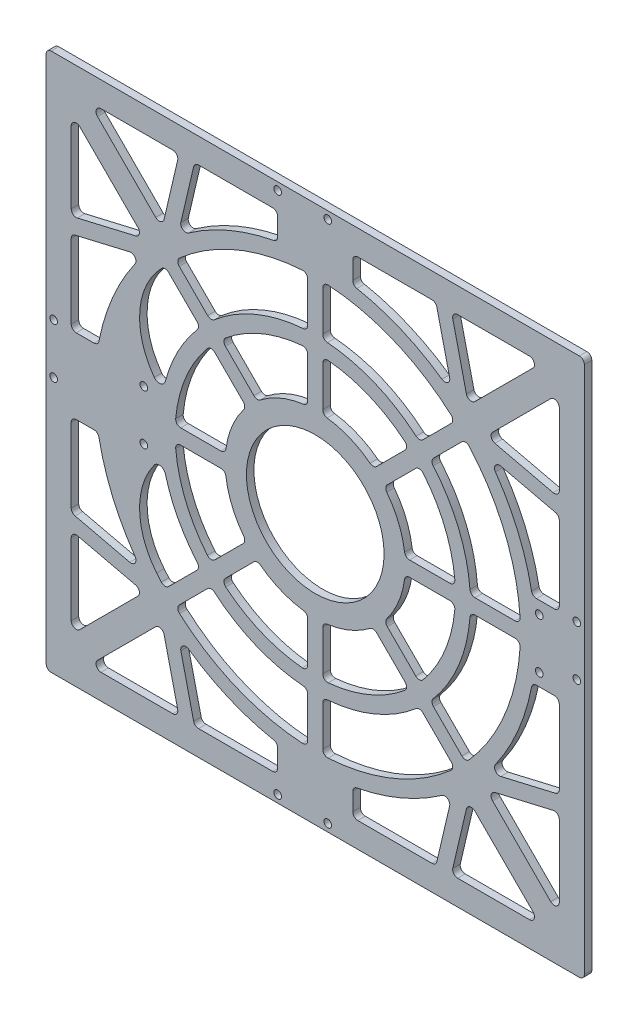
from build123d import *

# Parameters (mm, degrees)
SKETCH_1_W                  = 215
SKETCH_1_H                  = 215
EXTRUDE_1_DEPTH             = 1.5
SKETCH_2_R                  = 2.5
CUT_EXTRUDE_1_DEPTH         = 10
SKETCH_3_R                  = 1.525
CUT_EXTRUDE_2_DEPTH         = 30
HOLE_WIZARD_M3_1_AT_2_COUNT = 2
HOLE_WIZARD_M3_1_AT_2_PITCH = 22
HOLE_WIZARD_M3_1_AT_3_COUNT = 2
HOLE_WIZARD_M3_1_AT_3_PITCH = 38.105117767
HOLE_WIZARD_M3_1_AT_4_COUNT = 2
HOLE_WIZARD_M3_1_AT_4_PITCH = 44
HOLE_WIZARD_M3_1_AT_5_COUNT = 2
HOLE_WIZARD_M3_1_AT_5_PITCH = 38.105117767
HOLE_WIZARD_M3_1_AT_6_COUNT = 2
HOLE_WIZARD_M3_1_AT_6_PITCH = 22
SKETCH_6_R                  = 1.525
CUT_EXTRUDE_3_DEPTH         = 10
SKETCH_7_R                  = 1.525
CUT_EXTRUDE_4_DEPTH         = 10
CUT_EXTRUDE_5_DEPTH         = 10
FILLET_1_R                  = 2
FILLET_2_R                  = 2
CUT_EXTRUDE_6_DEPTH         = 10
PATTERN_CIRCULAR_1_COUNT    = 4
FILLET_3_R                  = 2
EXTRUDE_2_DEPTH             = 3
PATTERN_CIRCULAR_2_COUNT    = 4
FILLET_4_R                  = 2
EXTRUDE_3_DEPTH             = 3
PATTERN_CIRCULAR_3_COUNT    = 4
FILLET_5_R                  = 2
SKETCH_12_R                 = 36
EXTRUDE_4_DEPTH             = 3
SKETCH_13_R                 = 27.5
CUT_EXTRUDE_7_DEPTH         = 3
EXTRUDE_5_DEPTH             = 3
SKETCH_15_R                 = 1.525
CUT_EXTRUDE_8_DEPTH         = 10


with BuildPart() as part:
    # Sketch 1 → Extrude 1 (new body, symmetric)
    with BuildSketch(Plane.XY):
        Rectangle(SKETCH_1_W, SKETCH_1_H)
    extrude(amount=EXTRUDE_1_DEPTH, both=True)

    # Sketch 2 → Cut-Extrude 1 (cut)
    with BuildSketch(Plane.XY.offset(1.5)):
        Circle(SKETCH_2_R)
    extrude(amount=-CUT_EXTRUDE_1_DEPTH, mode=Mode.SUBTRACT)

    # Sketch 3 → Cut-Extrude 2 (cut)
    with BuildSketch(Plane.XY.offset(1.5)):
        with Locations((0, 22)):
            Circle(SKETCH_3_R)
        with Locations((19.052558883, 11)):
            Circle(SKETCH_3_R)
        with Locations((19.052558883, -11)):
            Circle(SKETCH_3_R)
        with Locations((0, -22)):
            Circle(SKETCH_3_R)
        with Locations((-19.052558883, -11)):
            Circle(SKETCH_3_R)
        with Locations((-19.052558883, 11)):
            Circle(SKETCH_3_R)
    extrude(amount=-CUT_EXTRUDE_2_DEPTH, mode=Mode.SUBTRACT)

    # Sketch 5 → Hole Wizard M3 _1 (revolve, cut)
    with BuildSketch(Plane(origin=(0, 22, -1.5), x_dir=(0, 1, 0), z_dir=(1, 0, 0))):
        Polygon((0, 0), (0, 3), (1.5, 3), (1.5, 1.8), (3.3, 0), align=None)
    hole_wizard_m3_1 = revolve(axis=Axis((0, 22, -7.85), (0, 0, 1)), mode=Mode.SUBTRACT)

    # Hole Wizard M3 _1 at 2: Hole Wizard M3 _1 ×2
    with Locations(*[Vector(-0.866025404, -0.5, 0) * (i * HOLE_WIZARD_M3_1_AT_2_PITCH) for i in range(1, HOLE_WIZARD_M3_1_AT_2_COUNT)]):
        add(hole_wizard_m3_1, mode=Mode.SUBTRACT)

    # Hole Wizard M3 _1 at 3: Hole Wizard M3 _1 ×2
    with Locations(*[Vector(-0.5, -0.866025404, 0) * (i * HOLE_WIZARD_M3_1_AT_3_PITCH) for i in range(1, HOLE_WIZARD_M3_1_AT_3_COUNT)]):
        add(hole_wizard_m3_1, mode=Mode.SUBTRACT)

    # Hole Wizard M3 _1 at 4: Hole Wizard M3 _1 ×2
    with Locations(*[(0, -i * HOLE_WIZARD_M3_1_AT_4_PITCH, 0) for i in range(1, HOLE_WIZARD_M3_1_AT_4_COUNT)]):
        add(hole_wizard_m3_1, mode=Mode.SUBTRACT)

    # Hole Wizard M3 _1 at 5: Hole Wizard M3 _1 ×2
    with Locations(*[Vector(0.5, -0.866025404, 0) * (i * HOLE_WIZARD_M3_1_AT_5_PITCH) for i in range(1, HOLE_WIZARD_M3_1_AT_5_COUNT)]):
        add(hole_wizard_m3_1, mode=Mode.SUBTRACT)

    # Hole Wizard M3 _1 at 6: Hole Wizard M3 _1 ×2
    with Locations(*[Vector(0.866025404, -0.5, 0) * (i * HOLE_WIZARD_M3_1_AT_6_PITCH) for i in range(1, HOLE_WIZARD_M3_1_AT_6_COUNT)]):
        add(hole_wizard_m3_1, mode=Mode.SUBTRACT)

    # Sketch 6 → Cut-Extrude 3 (cut)
    with BuildSketch(Plane.XY.offset(1.5)):
        with Locations((5, -104.5)):
            Circle(SKETCH_6_R)
        with Locations((-15, -104.5)):
            Circle(SKETCH_6_R)
    cut_extrude_3 = extrude(amount=-CUT_EXTRUDE_3_DEPTH, mode=Mode.SUBTRACT)

    # Mirror 1: Cut-Extrude 3 across plane
    add(cut_extrude_3.mirror(Plane.ZX), mode=Mode.SUBTRACT)

    # Sketch 7 → Cut-Extrude 4 (cut)
    with BuildSketch(Plane(origin=(0, 0, -1.5), x_dir=(-1, 0, 0), z_dir=(0, 0, -1))):
        with Locations((104.5, 15)):
            Circle(SKETCH_7_R)
        with Locations((104.5, -5)):
            Circle(SKETCH_7_R)
    cut_extrude_4 = extrude(amount=-CUT_EXTRUDE_4_DEPTH, mode=Mode.SUBTRACT)

    # Mirror 2: Cut-Extrude 4 across plane
    add(cut_extrude_4.mirror(Plane(origin=(0, 0, 0), x_dir=(0, 0, 1), z_dir=(1, 0, 0))), mode=Mode.SUBTRACT)

    # Sketch 8 → Cut-Extrude 5 (cut)
    with BuildSketch(Plane(origin=(0, 0, -1.5), x_dir=(-1, 0, 0), z_dir=(0, 0, -1))):
        with BuildLine():
            Line((3, -61.927376822), (3, -81.945103576))
            ThreePointArc((3, -81.945103576), (31.380041454, -75.758121666), (55.82261808, -60.065258767))
            Line((55.82261808, -60.065258767), (41.667947748, -45.910588435))
            ThreePointArc((41.667947748, -45.910588435), (23.726372807, -57.280531016), (3, -61.927376822))
        make_face()
        with BuildLine():
            ThreePointArc((60.065258767, -55.82261808), (75.758121666, -31.380041454), (81.945103576, -3))
            Line((81.945103576, -3), (61.927376822, -3))
            ThreePointArc((61.927376822, -3), (57.280531016, -23.726372807), (45.910588435, -41.667947748))
            Line((45.910588435, -41.667947748), (60.065258767, -55.82261808))
        make_face()
        with BuildLine():
            ThreePointArc((81.945103576, 3), (75.758121666, 31.380041454), (60.065258767, 55.82261808))
            Line((60.065258767, 55.82261808), (45.910588435, 41.667947748))
            ThreePointArc((45.910588435, 41.667947748), (57.280531016, 23.726372807), (61.927376822, 3))
            Line((61.927376822, 3), (81.945103576, 3))
        make_face()
        with BuildLine():
            ThreePointArc((55.82261808, 60.065258767), (31.380041454, 75.758121666), (3, 81.945103576))
            Line((3, 81.945103576), (3, 61.927376822))
            ThreePointArc((3, 61.927376822), (23.726372807, 57.280531016), (41.667947748, 45.910588435))
            Line((41.667947748, 45.910588435), (55.82261808, 60.065258767))
        make_face()
        with BuildLine():
            ThreePointArc((-3, 81.945103576), (-31.380041454, 75.758121666), (-55.82261808, 60.065258767))
            Line((-55.82261808, 60.065258767), (-41.667947748, 45.910588435))
            ThreePointArc((-41.667947748, 45.910588435), (-23.726372807, 57.280531016), (-3, 61.927376822))
            Line((-3, 61.927376822), (-3, 81.945103576))
        make_face()
        with BuildLine():
            Line((-45.910588435, 41.667947748), (-60.065258767, 55.82261808))
            ThreePointArc((-60.065258767, 55.82261808), (-75.758121666, 31.380041454), (-81.945103576, 3))
            Line((-81.945103576, 3), (-61.927376822, 3))
            ThreePointArc((-61.927376822, 3), (-57.280531016, 23.726372807), (-45.910588435, 41.667947748))
        make_face()
        with BuildLine():
            Line((-61.927376822, -3), (-81.945103576, -3))
            ThreePointArc((-81.945103576, -3), (-75.758121666, -31.380041454), (-60.065258767, -55.82261808))
            Line((-60.065258767, -55.82261808), (-45.910588435, -41.667947748))
            ThreePointArc((-45.910588435, -41.667947748), (-57.280531016, -23.726372807), (-61.927376822, -3))
        make_face()
        with BuildLine():
            Line((-35.874782229, -3), (-55.91958512, -3))
            ThreePointArc((-55.91958512, -3), (-51.737253821, -21.430272212), (-41.662438183, -37.419797496))
            Line((-41.662438183, -37.419797496), (-27.488622131, -23.245981444))
            ThreePointArc((-27.488622131, -23.245981444), (-33.25966317, -13.776603565), (-35.874782229, -3))
        make_face()
        with BuildLine():
            Line((-23.245981444, -27.488622131), (-37.419797496, -41.662438183))
            ThreePointArc((-37.419797496, -41.662438183), (-21.430272212, -51.737253821), (-3, -55.91958512))
            Line((-3, -55.91958512), (-3, -35.874782229))
            ThreePointArc((-3, -35.874782229), (-13.776603565, -33.25966317), (-23.245981444, -27.488622131))
        make_face()
        with BuildLine():
            Line((-41.667947748, -45.910588435), (-55.82261808, -60.065258767))
            ThreePointArc((-55.82261808, -60.065258767), (-31.380041454, -75.758121666), (-3, -81.945103576))
            Line((-3, -81.945103576), (-3, -61.927376822))
            ThreePointArc((-3, -61.927376822), (-23.726372807, -57.280531016), (-41.667947748, -45.910588435))
        make_face()
        with BuildLine():
            Line((3, -35.874782229), (3, -55.91958512))
            ThreePointArc((3, -55.91958512), (21.430272212, -51.737253821), (37.419797496, -41.662438183))
            Line((37.419797496, -41.662438183), (23.245981444, -27.488622131))
            ThreePointArc((23.245981444, -27.488622131), (13.776603565, -33.25966317), (3, -35.874782229))
        make_face()
        with BuildLine():
            ThreePointArc((41.662438183, -37.419797496), (51.737253821, -21.430272212), (55.91958512, -3))
            Line((55.91958512, -3), (35.874782229, -3))
            ThreePointArc((35.874782229, -3), (33.25966317, -13.776603565), (27.488622131, -23.245981444))
            Line((27.488622131, -23.245981444), (41.662438183, -37.419797496))
        make_face()
        with BuildLine():
            ThreePointArc((55.91958512, 3), (51.737253821, 21.430272212), (41.662438183, 37.419797496))
            Line((41.662438183, 37.419797496), (27.488622131, 23.245981444))
            ThreePointArc((27.488622131, 23.245981444), (33.25966317, 13.776603565), (35.874782229, 3))
            Line((35.874782229, 3), (55.91958512, 3))
        make_face()
        with BuildLine():
            ThreePointArc((37.419797496, 41.662438183), (21.430272212, 51.737253821), (3, 55.91958512))
            Line((3, 55.91958512), (3, 35.874782229))
            ThreePointArc((3, 35.874782229), (13.776603565, 33.25966317), (23.245981444, 27.488622131))
            Line((23.245981444, 27.488622131), (37.419797496, 41.662438183))
        make_face()
        with BuildLine():
            ThreePointArc((-3, 55.91958512), (-21.430272212, 51.737253821), (-37.419797496, 41.662438183))
            Line((-37.419797496, 41.662438183), (-23.245981444, 27.488622131))
            ThreePointArc((-23.245981444, 27.488622131), (-13.776603565, 33.25966317), (-3, 35.874782229))
            Line((-3, 35.874782229), (-3, 55.91958512))
        make_face()
        with BuildLine():
            Line((-27.488622131, 23.245981444), (-41.662438183, 37.419797496))
            ThreePointArc((-41.662438183, 37.419797496), (-51.737253821, 21.430272212), (-55.91958512, 3))
            Line((-55.91958512, 3), (-35.874782229, 3))
            ThreePointArc((-35.874782229, 3), (-33.25966317, 13.776603565), (-27.488622131, 23.245981444))
        make_face()
    extrude(amount=-CUT_EXTRUDE_5_DEPTH, mode=Mode.SUBTRACT)

    # Fillet 1
    fillet_1_edges = [part.edges().sort_by_distance(p)[0] for p in [
        (60.065258767, 55.82261808, 0),
        (45.910588435, 41.667947748, 0),
        (61.927376822, 3, 0),
        (81.945103576, 3, 0),
        (81.945103576, -3, 0),
        (61.927376822, -3, 0),
        (45.910588435, -41.667947748, 0),
        (60.065258767, -55.82261808, 0),
        (37.419797496, -41.662438183, 0),
        (23.245981444, -27.488622131, 0),
        (3, -35.874782229, 0),
        (3, -55.91958512, 0),
        (55.91958512, -3, 0),
        (35.874782229, -3, 0),
        (27.488622131, -23.245981444, 0),
        (41.662438183, -37.419797496, 0),
        (-60.065258767, -55.82261808, 0),
        (-45.910588435, -41.667947748, 0),
        (-61.927376822, -3, 0),
        (-81.945103576, -3, 0),
        (-81.945103576, 3, 0),
        (-61.927376822, 3, 0),
        (-45.910588435, 41.667947748, 0),
        (-60.065258767, 55.82261808, 0),
        (-55.82261808, 60.065258767, 0),
        (-41.667947748, 45.910588435, 0),
        (-3, 61.927376822, 0),
        (-3, 81.945103576, 0),
        (3, 81.945103576, 0),
        (3, 61.927376822, 0),
        (41.667947748, 45.910588435, 0),
        (55.82261808, 60.065258767, 0),
        (-37.419797496, 41.662438183, 0),
        (-23.245981444, 27.488622131, 0),
        (-3, 35.874782229, 0),
        (-3, 55.91958512, 0),
        (3, 55.91958512, 0),
        (3, 35.874782229, 0),
        (23.245981444, 27.488622131, 0),
        (37.419797496, 41.662438183, 0),
        (41.662438183, 37.419797496, 0),
        (27.488622131, 23.245981444, 0),
        (35.874782229, 3, 0),
        (55.91958512, 3, 0),
        (55.82261808, -60.065258767, 0),
        (41.667947748, -45.910588435, 0),
        (3, -61.927376822, 0),
        (3, -81.945103576, 0),
        (-3, -55.91958512, 0),
        (-3, -35.874782229, 0),
        (-23.245981444, -27.488622131, 0),
        (-37.419797496, -41.662438183, 0),
        (-41.662438183, -37.419797496, 0),
        (-27.488622131, -23.245981444, 0),
        (-35.874782229, -3, 0),
        (-55.91958512, -3, 0),
        (-55.91958512, 3, 0),
        (-35.874782229, 3, 0),
        (-27.488622131, 23.245981444, 0),
        (-41.662438183, 37.419797496, 0),
        (-3, -81.945103576, 0),
        (-3, -61.927376822, 0),
        (-41.667947748, -45.910588435, 0),
        (-55.82261808, -60.065258767, 0),
    ]]
    fillet(fillet_1_edges, radius=FILLET_1_R)

    # Fillet 2
    fillet_2_edges = [part.edges().sort_by_distance(p)[0] for p in [
        (107.5, -107.5, 0),
        (-107.5, -107.5, 0),
        (-107.5, 107.5, 0),
        (107.5, 107.5, 0),
    ]]
    fillet(fillet_2_edges, radius=FILLET_2_R)

    # Sketch 9 → Cut-Extrude 6 (cut)
    with BuildSketch(Plane(origin=(0, 0, -1.5), x_dir=(-1, 0, 0), z_dir=(0, 0, -1))):
        with BuildLine():
            ThreePointArc((-15, -86.712167543), (-38.270640134, -79.242400921), (-58.589340339, -65.660408151))
            Line((-58.589340339, -65.660408151), (-90.428932188, -97.5))
            Line((-90.428932188, -97.5), (-15, -97.5))
            Line((-15, -97.5), (-15, -86.712167543))
        make_face()
        with BuildLine():
            ThreePointArc((-65.660408151, -58.589340339), (-79.242400921, -38.270640134), (-86.712167543, -15))
            Line((-86.712167543, -15), (-97.5, -15))
            Line((-97.5, -15), (-97.5, -90.428932188))
            Line((-97.5, -90.428932188), (-65.660408151, -58.589340339))
        make_face()
    cut_extrude_6 = extrude(amount=-CUT_EXTRUDE_6_DEPTH, mode=Mode.SUBTRACT)

    # Pattern Circular 1: Cut-Extrude 6 ×4 about axis
    pattern_circular_1_axis = Axis((0, 0, 0), (0, 0, 1))
    for i in range(1, PATTERN_CIRCULAR_1_COUNT):
        add(cut_extrude_6.rotate(pattern_circular_1_axis, i * 360 / PATTERN_CIRCULAR_1_COUNT), mode=Mode.SUBTRACT)

    # Fillet 3
    fillet_3_edges = [part.edges().sort_by_distance(p)[0] for p in [
        (86.712167543, -15, 0),
        (65.660408151, -58.589340339, 0),
        (97.5, -90.428932188, 0),
        (97.5, -15, 0),
        (58.589340339, -65.660408151, 0),
        (15, -86.712167543, 0),
        (15, -97.5, 0),
        (90.428932188, -97.5, 0),
        (-65.660408151, -58.589340339, 0),
        (-86.712167543, -15, 0),
        (-97.5, -15, 0),
        (-97.5, -90.428932188, 0),
        (-86.712167543, 15, 0),
        (-65.660408151, 58.589340339, 0),
        (-97.5, 90.428932188, 0),
        (-97.5, 15, 0),
        (-58.589340339, 65.660408151, 0),
        (-15, 86.712167543, 0),
        (-15, 97.5, 0),
        (-90.428932188, 97.5, 0),
        (15, 86.712167543, 0),
        (58.589340339, 65.660408151, 0),
        (90.428932188, 97.5, 0),
        (15, 97.5, 0),
        (-15, -86.712167543, 0),
        (-58.589340339, -65.660408151, 0),
        (-90.428932188, -97.5, 0),
        (-15, -97.5, 0),
        (65.660408151, 58.589340339, 0),
        (86.712167543, 15, 0),
        (97.5, 15, 0),
        (97.5, 90.428932188, 0),
    ]]
    fillet(fillet_3_edges, radius=FILLET_3_R)

    # Sketch 10 → Extrude 2 (add)
    with BuildSketch(Plane.XY.offset(1.5)):
        Polygon((48.219283011, 97.5), (55.65375901, 65.714838596), (61.862229573, 65.515898963), (54.221410933, 98.183252218), align=None)
    extrude_2 = extrude(amount=-EXTRUDE_2_DEPTH)

    # Pattern Circular 2: Extrude 2 ×4 about axis
    pattern_circular_2_axis = Axis((0, 0, 0), (0, 0, 1))
    for i in range(1, PATTERN_CIRCULAR_2_COUNT):
        add(extrude_2.rotate(pattern_circular_2_axis, i * 360 / PATTERN_CIRCULAR_2_COUNT))

    # Fillet 4
    fillet_4_edges = [part.edges().sort_by_distance(p)[0] for p in [
        (54.381222052, 97.5, 0),
        (61.214427394, 68.285495206, 0),
        (54.946746519, 68.737581038, 0),
        (48.219283011, 97.5, 0),
        (97.5, -54.381222052, 0),
        (68.285495206, -61.214427394, 0),
        (68.737581038, -54.946746519, 0),
        (97.5, -48.219283011, 0),
        (-54.381222052, -97.5, 0),
        (-61.214427394, -68.285495206, 0),
        (-54.946746519, -68.737581038, 0),
        (-48.219283011, -97.5, 0),
        (-97.5, 54.381222052, 0),
        (-68.285495206, 61.214427394, 0),
        (-68.737581038, 54.946746519, 0),
        (-97.5, 48.219283011, 0),
    ]]
    fillet(fillet_4_edges, radius=FILLET_4_R)

    # Sketch 11 → Extrude 3 (add)
    with BuildSketch(Plane.XY.offset(1.5)):
        Polygon((61.62400433, 56.610595716), (97.5, 48.219283011), (98.183252218, 54.221410933), (67.081343032, 61.496075813), align=None)
    extrude_3 = extrude(amount=-EXTRUDE_3_DEPTH)

    # Pattern Circular 3: Extrude 3 ×4 about axis
    pattern_circular_3_axis = Axis((0, 0, 0), (0, 0, 1))
    for i in range(1, PATTERN_CIRCULAR_3_COUNT):
        add(extrude_3.rotate(pattern_circular_3_axis, i * 360 / PATTERN_CIRCULAR_3_COUNT))

    # Fillet 5
    fillet_5_edges = [part.edges().sort_by_distance(p)[0] for p in [
        (68.285495206, 61.214427394, 0),
        (68.737581038, 54.946746519, 0),
        (97.5, 48.219283011, 0),
        (97.5, 54.381222052, 0),
        (-61.214427394, 68.285495206, 0),
        (-54.946746519, 68.737581038, 0),
        (-48.219283011, 97.5, 0),
        (-54.381222052, 97.5, 0),
        (-68.285495206, -61.214427394, 0),
        (-68.737581038, -54.946746519, 0),
        (-97.5, -48.219283011, 0),
        (-97.5, -54.381222052, 0),
        (61.214427394, -68.285495206, 0),
        (54.946746519, -68.737581038, 0),
        (48.219283011, -97.5, 0),
        (54.381222052, -97.5, 0),
    ]]
    fillet(fillet_5_edges, radius=FILLET_5_R)

    # Sketch 12 → Extrude 4 (add)
    with BuildSketch(Plane.XY.offset(1.5)):
        Circle(SKETCH_12_R)
    extrude(amount=-EXTRUDE_4_DEPTH)

    # Sketch 13 → Cut-Extrude 7 (cut)
    with BuildSketch(Plane.XY.offset(1.5)):
        Circle(SKETCH_13_R)
    extrude(amount=-CUT_EXTRUDE_7_DEPTH, mode=Mode.SUBTRACT)

    # Sketch 14 → Extrude 5 (add)
    with BuildSketch(Plane.XY.offset(1.5)):
        with BuildLine():
            ThreePointArc((-63.804388564, 3), (-62.446541002, 3.531582484), (-61.810501421, 4.84375))
            ThreePointArc((-61.810501421, 4.84375), (-61.108652364, 10.475333231), (-59.894798615, 16.019147881))
            ThreePointArc((-59.894798615, 16.019147881), (-61.844295847, 14.20882378), (-64.321079422, 15.180088895))
            ThreePointArc((-64.321079422, 15.180088895), (-70.177120133, 33.772300997), (-63.371906249, 52.038461721))
            ThreePointArc((-63.371906249, 52.038461721), (-76.300851431, 30.036312537), (-81.839687041, 5.125))
            ThreePointArc((-81.839687041, 5.125), (-81.301335087, 3.630693606), (-79.843597113, 3))
            Line((-79.843597113, 3), (-63.804388564, 3))
        make_face()
    extrude_5 = extrude(amount=-EXTRUDE_5_DEPTH)

    # Mirror 3: Extrude 5 across plane
    add(extrude_5.mirror(Plane.ZX))

    # Sketch 15 → Cut-Extrude 8 (cut)
    with BuildSketch(Plane(origin=(0, 0, -1.5), x_dir=(-1, 0, 0), z_dir=(0, 0, -1))):
        with Locations((-89.5, -10)):
            Circle(SKETCH_15_R)
        with Locations((-89.5, 10)):
            Circle(SKETCH_15_R)
        with Locations((68.5, -10)):
            Circle(SKETCH_15_R)
        with Locations((68.5, 10)):
            Circle(SKETCH_15_R)
    extrude(amount=-CUT_EXTRUDE_8_DEPTH, mode=Mode.SUBTRACT)


solid = part.part
